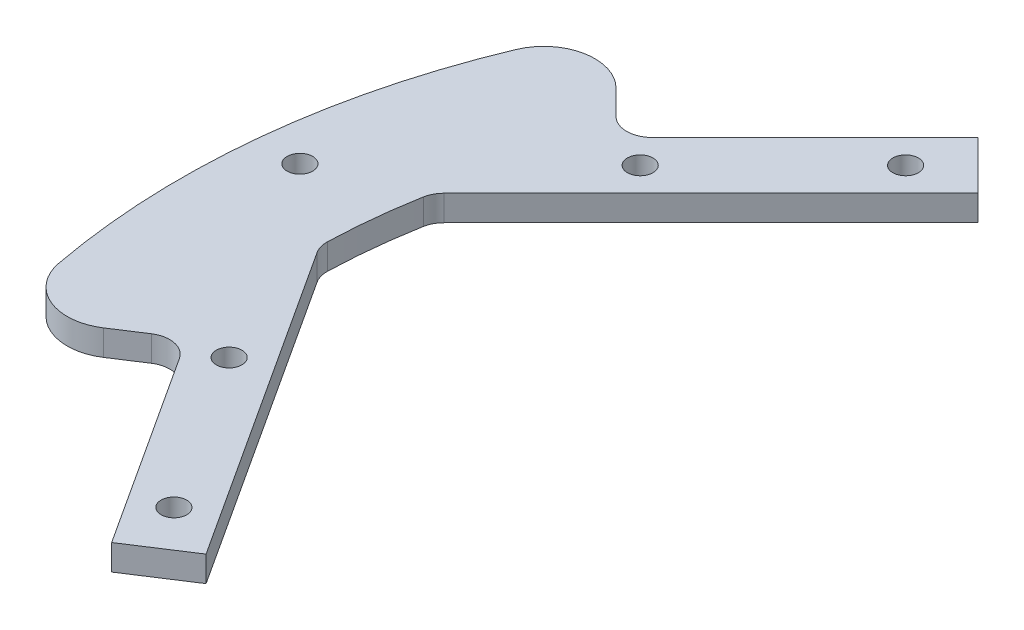
from build123d import *

# Parameters (mm, degrees)
SKETCH1_R           = 1.5
BOSS_EXTRUDE1_DEPTH = 3
FILLET1_R           = 6
FILLET2_R           = 3
CUT_EXTRUDE1_REACH  = 5
SKETCH2_R           = 1.5


with BuildPart() as part:
    # Sketch1 → Boss-Extrude1 (new body)
    with BuildSketch(Plane(origin=(0, 0, 0), x_dir=(1, 0, 0), z_dir=(0, 1, 0))):
        with BuildLine():
            Line((-74.629040009, 40.687914512), (-63.639610307, 29.69848481))
            Line((-63.639610307, 29.69848481), (-42.426406871, 50.911688245))
            Line((-42.426406871, 50.911688245), (-36.769552622, 45.254833996))
            Line((-36.769552622, 45.254833996), (-68.72500623, 13.299380388))
            ThreePointArc((-68.72500623, 13.299380388), (-69.616532676, 7.316992429), (-69.988296617, 1.279975229))
            Line((-69.988296617, 1.279975229), (-45.375058731, -36.621087439))
            Line((-45.375058731, -36.621087439), (-52.084423274, -40.978199719))
            Line((-52.084423274, -40.978199719), (-68.423594325, -15.81808268))
            Line((-68.423594325, -15.81808268), (-81.457709532, -24.282536066))
            ThreePointArc((-81.457709532, -24.282536066), (-84.534361106, 8.884919378), (-74.629040009, 40.687914512))
        make_face()
        with Locations((-43.840620434, 43.840620434)):
            Circle(SKETCH1_R, mode=Mode.SUBTRACT)
        with Locations((-59.39696962, 28.284271247)):
            Circle(SKETCH1_R, mode=Mode.SUBTRACT)
        with Locations((-51.997575213, -33.767620171)):
            Circle(SKETCH1_R, mode=Mode.SUBTRACT)
        with Locations((-63.979633983, -15.316867676)):
            Circle(SKETCH1_R, mode=Mode.SUBTRACT)
    extrude(amount=BOSS_EXTRUDE1_DEPTH)

    # Fillet1
    fillet1_edges = [part.edges().sort_by_distance(p)[0] for p in [
        (-74.629040009, 1.5, -40.687914512),
        (-81.457709532, 1.5, 24.282536066),
    ]]
    fillet(fillet1_edges, radius=FILLET1_R)

    # Fillet2
    fillet2_edges = [part.edges().sort_by_distance(p)[0] for p in [
        (-63.639610307, 1.5, -29.69848481),
        (-68.72500623, 1.5, -13.299380388),
        (-69.988296617, 1.5, -1.279975229),
        (-68.423594325, 1.5, 15.81808268),
    ]]
    fillet(fillet2_edges, radius=FILLET2_R)

    # Sketch2 → Cut-Extrude1 (cut, up to next)
    with BuildSketch(Plane(origin=(0, 3, 0), x_dir=(1, 0, 0), z_dir=(0, 1, 0)), mode=Mode.PRIVATE) as cut_extrude1_sk1:
        with Locations((-79.5, 8.5)):
            Circle(SKETCH2_R)
    cut_extrude1_tool1 = extrude(cut_extrude1_sk1.sketch, amount=-CUT_EXTRUDE1_REACH, mode=Mode.PRIVATE) & part.part
    add(cut_extrude1_tool1.solids().sort_by_distance((-79.5, 3, -8.5))[0], mode=Mode.SUBTRACT)


solid = part.part
